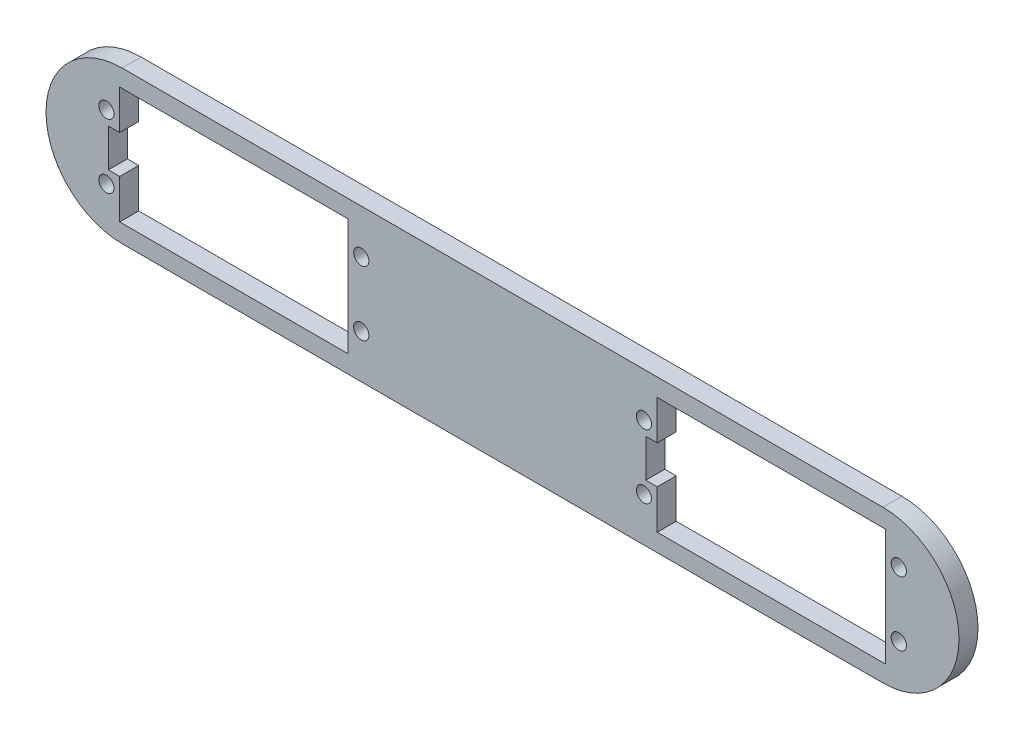
from build123d import *

# Parameters (mm, degrees)
BOSS_EXTRUDE1_DEPTH = 5
SKETCH2_R           = 2
SKETCH2_R_2         = 1.979542606
CUT_EXTRUDE1_DEPTH  = 10
SKETCH3_R           = 2
CUT_EXTRUDE2_DEPTH  = 10


with BuildPart() as part:
    # Sketch1 → Boss-Extrude1 (new body)
    with BuildSketch(Plane.XY):
        with BuildLine():
            Line((0, 20), (200, 20))
            ThreePointArc((200, 20), (220, 0), (200, -20))
            Line((200, -20), (0, -20))
            ThreePointArc((0, -20), (-20, 0), (0, 20))
        make_face()
        Polygon((-0.621565279, -5), (-0.621565279, -15.35), (59.378434721, -15.35), (59.378434721, 15.35), (-0.621565279, 15.35), (-0.621565279, 5), (-3.621565279, 5), (-3.621565279, -5), align=None, mode=Mode.SUBTRACT)
        Polygon((140.672709247, -5), (140.672709247, -15.35), (200.672709247, -15.35), (200.672709247, 15.35), (140.672709247, 15.35), (140.672709247, 5), (137.672709247, 5), (137.672709247, -5), align=None, mode=Mode.SUBTRACT)
    extrude(amount=BOSS_EXTRUDE1_DEPTH)

    # Sketch2 → Cut-Extrude1 (cut)
    with BuildSketch(Plane(origin=(0, 0, 0), x_dir=(-1, 0, 0), z_dir=(0, 0, -1))):
        with Locations((-137.172709247, 8.45)):
            Circle(SKETCH2_R)
        with Locations((-137.172709247, -8.45)):
            Circle(SKETCH2_R_2)
        with Locations((-204.172709247, 8.45)):
            Circle(SKETCH2_R)
        with Locations((-204.172709247, -8.45)):
            Circle(SKETCH2_R)
    extrude(amount=-CUT_EXTRUDE1_DEPTH, mode=Mode.SUBTRACT)

    # Sketch3 → Cut-Extrude2 (cut)
    with BuildSketch(Plane(origin=(0, 0, 0), x_dir=(-1, 0, 0), z_dir=(0, 0, -1))):
        with Locations((4.121565279, 8.45)):
            Circle(SKETCH3_R)
        with Locations((4.121565279, -8.45)):
            Circle(SKETCH3_R)
        with Locations((-62.878434721, -8.45)):
            Circle(SKETCH3_R)
        with Locations((-62.878434721, 8.45)):
            Circle(SKETCH3_R)
    extrude(amount=-CUT_EXTRUDE2_DEPTH, mode=Mode.SUBTRACT)


solid = part.part
